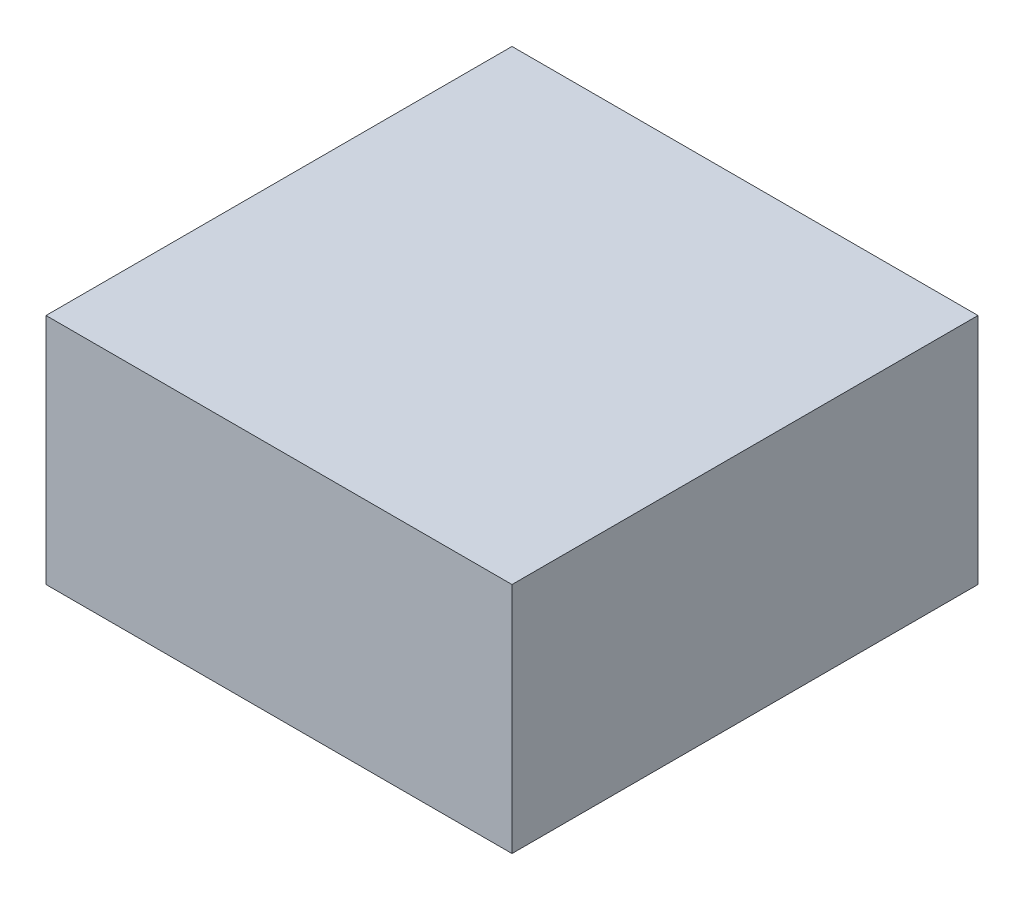
from build123d import *

# Parameters (mm, degrees)
CROQUIS1_W              = 400
CROQUIS1_H              = 400
SALIENTE_EXTRUIR1_DEPTH = 200


with BuildPart() as part:
    # Croquis1 → Saliente-Extruir1 (new body)
    with BuildSketch(Plane(origin=(0, 0, 0), x_dir=(1, 0, 0), z_dir=(0, 1, 0))):
        with Locations((200, 200)):
            Rectangle(CROQUIS1_W, CROQUIS1_H)
    extrude(amount=SALIENTE_EXTRUIR1_DEPTH)


solid = part.part
